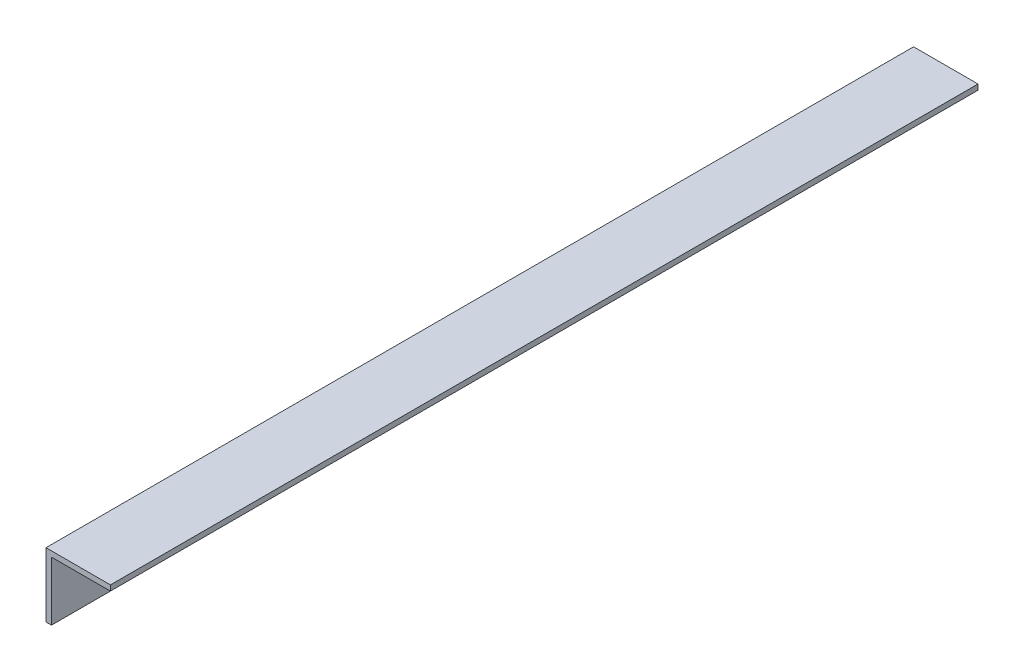
from build123d import *

# Parameters (mm, degrees)
BOSS_EXTRUDE1_DEPTH = 256.54


with BuildPart() as part:
    # Sketch1 → Boss-Extrude1 (new body)
    with BuildSketch(Plane.XY):
        Polygon((0, 0), (-19.05, 0), (-19.05, -19.05), (-17.4498, -19.05), (-17.4498, -1.6002), (0, -1.6002), align=None)
    extrude(amount=BOSS_EXTRUDE1_DEPTH)


solid = part.part
